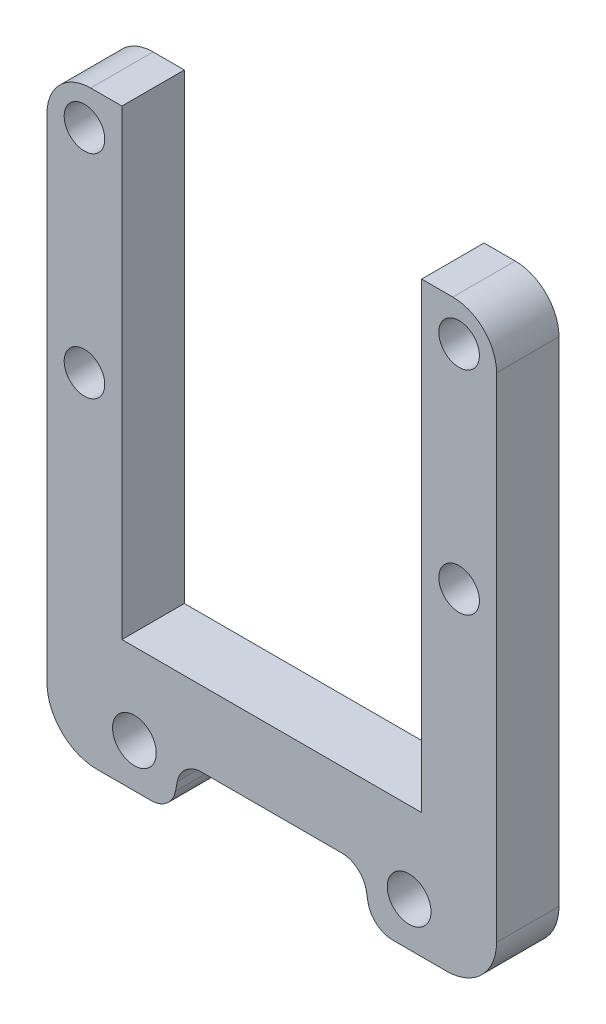
from build123d import *

# Parameters (mm, degrees)
ESQUISSE1_R        = 3.25
ESQUISSE1_R_2      = 3.5
BOSS_EXTRU_1_DEPTH = 10
CONG_1_R           = 4
CONG_2_R           = 8
CONG_3_R           = 7


with BuildPart() as part:
    # Esquisse1 → Boss.-Extru.1 (new body)
    with BuildSketch(Plane.XY):
        Polygon((24, 110), (24, 36), (0, 36), (0, 24), (14.5, 24), (16.055042473, 16), (36, 16), (36, 110), align=None)
        with Locations((30, 104)):
            Circle(ESQUISSE1_R, mode=Mode.SUBTRACT)
        with Locations((22, 23)):
            Circle(ESQUISSE1_R_2, mode=Mode.SUBTRACT)
        with Locations((30, 70)):
            Circle(ESQUISSE1_R, mode=Mode.SUBTRACT)
    boss_extru_1 = extrude(amount=BOSS_EXTRU_1_DEPTH)

    # Symétrie2: Boss.-Extru.1 across plane
    add(boss_extru_1.mirror(Plane(origin=(0, 36, 10), x_dir=(0, 0, 1), z_dir=(1, 0, 0))))

    # Congé1
    cong_1_edges = [part.edges().sort_by_distance(p)[0] for p in [
        (16.055042473, 16, 5),
        (14.5, 24, 5),
        (-14.5, 24, 5),
        (-16.055042473, 16, 5),
    ]]
    fillet(cong_1_edges, radius=CONG_1_R)

    # Congé2
    cong_2_edges = [part.edges().sort_by_distance(p)[0] for p in [
        (36, 16, 5),
        (-36, 16, 5),
    ]]
    fillet(cong_2_edges, radius=CONG_2_R)

    # Congé3
    cong_3_edges = [part.edges().sort_by_distance(p)[0] for p in [
        (36, 110, 5),
        (-36, 110, 5),
    ]]
    fillet(cong_3_edges, radius=CONG_3_R)


solid = part.part
